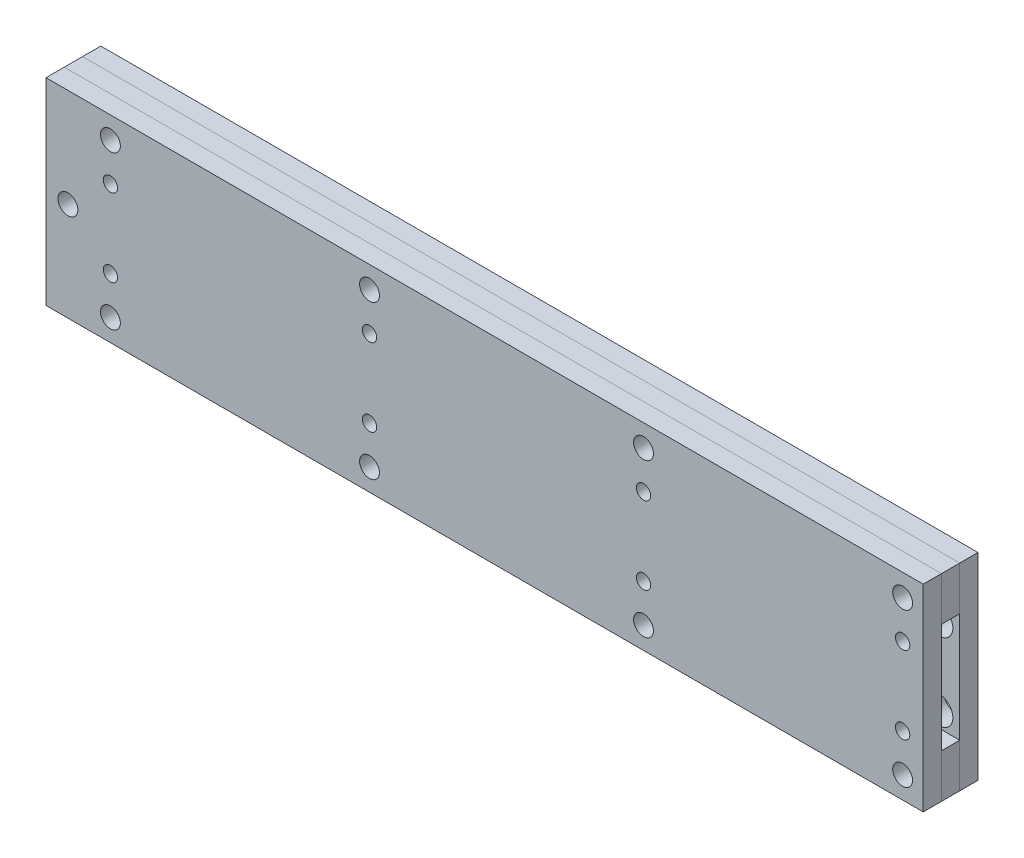
from build123d import *

# Parameters (mm, degrees)
CROQUIS3_W              = 304.927
CROQUIS3_H              = 68.58
CROQUIS3_R              = 2.4892
CROQUIS3_R_2            = 4.75615
SALIENTE_EXTRUIR1_DEPTH = 6.35
CROQUIS4_R              = 2.4892
SALIENTE_EXTRUIR2_DEPTH = 6.35
CROQUIS7_W              = 304.927
CROQUIS7_H              = 68.58
CROQUIS7_R              = 2.4892
CROQUIS7_R_2            = 3.45
SALIENTE_EXTRUIR4_DEPTH = 6.35


with BuildPart() as part:
    # Croquis3 → Saliente-Extruir1 (new body)
    with BuildSketch(Plane.XY):
        with Locations((-7.62, 0)):
            Rectangle(CROQUIS3_W, CROQUIS3_H)
        with Locations((-137.6934, -26.67)):
            Circle(CROQUIS3_R, mode=Mode.SUBTRACT)
        with Locations((-47.625, -26.67)):
            Circle(CROQUIS3_R, mode=Mode.SUBTRACT)
        with Locations((-137.6934, -13.4874)):
            Circle(CROQUIS3_R_2, mode=Mode.SUBTRACT)
        with Locations((-47.625, -13.4874)):
            Circle(CROQUIS3_R_2, mode=Mode.SUBTRACT)
        with Locations((47.625, -26.67)):
            Circle(CROQUIS3_R, mode=Mode.SUBTRACT)
        with Locations((137.6934, -26.67)):
            Circle(CROQUIS3_R, mode=Mode.SUBTRACT)
        with Locations((47.625, -13.4874)):
            Circle(CROQUIS3_R_2, mode=Mode.SUBTRACT)
        with Locations((137.6934, -13.4874)):
            Circle(CROQUIS3_R_2, mode=Mode.SUBTRACT)
        with Locations((-152.4635, 0)):
            Circle(CROQUIS3_R, mode=Mode.SUBTRACT)
        with Locations((-137.6934, 13.4874)):
            Circle(CROQUIS3_R_2, mode=Mode.SUBTRACT)
        with Locations((-47.625, 13.4874)):
            Circle(CROQUIS3_R_2, mode=Mode.SUBTRACT)
        with Locations((-137.6934, 26.67)):
            Circle(CROQUIS3_R, mode=Mode.SUBTRACT)
        with Locations((-47.625, 26.67)):
            Circle(CROQUIS3_R, mode=Mode.SUBTRACT)
        with Locations((47.625, 13.4874)):
            Circle(CROQUIS3_R_2, mode=Mode.SUBTRACT)
        with Locations((137.6934, 13.4874)):
            Circle(CROQUIS3_R_2, mode=Mode.SUBTRACT)
        with Locations((47.625, 26.67)):
            Circle(CROQUIS3_R, mode=Mode.SUBTRACT)
        with Locations((137.6934, 26.67)):
            Circle(CROQUIS3_R, mode=Mode.SUBTRACT)
    extrude(amount=SALIENTE_EXTRUIR1_DEPTH)


with BuildPart() as body_2:
    # Croquis4 → Saliente-Extruir2 (new body)
    with BuildSketch(Plane.XY.offset(6.35)):
        Polygon((144.8435, -19.05), (-144.8435, -19.05), (-144.8435, 19.05), (144.8435, 19.05), (144.8435, 34.29), (-160.0835, 34.29), (-160.0835, -34.29), (144.8435, -34.29), align=None)
        with Locations((-137.6934, -26.67)):
            Circle(CROQUIS4_R, mode=Mode.SUBTRACT)
        with Locations((-47.625, -26.67)):
            Circle(CROQUIS4_R, mode=Mode.SUBTRACT)
        with Locations((47.625, -26.67)):
            Circle(CROQUIS4_R, mode=Mode.SUBTRACT)
        with Locations((137.6934, -26.67)):
            Circle(CROQUIS4_R, mode=Mode.SUBTRACT)
        with Locations((-152.4635, 0)):
            Circle(CROQUIS4_R, mode=Mode.SUBTRACT)
        with Locations((-137.6934, 26.67)):
            Circle(CROQUIS4_R, mode=Mode.SUBTRACT)
        with Locations((-47.625, 26.67)):
            Circle(CROQUIS4_R, mode=Mode.SUBTRACT)
        with Locations((47.625, 26.67)):
            Circle(CROQUIS4_R, mode=Mode.SUBTRACT)
        with Locations((137.6934, 26.67)):
            Circle(CROQUIS4_R, mode=Mode.SUBTRACT)
    extrude(amount=SALIENTE_EXTRUIR2_DEPTH)


with BuildPart() as body_3:
    # Croquis7 → Saliente-Extruir4 (new body)
    with BuildSketch(Plane.XY.offset(12.7)):
        with Locations((-7.62, 0)):
            Rectangle(CROQUIS7_W, CROQUIS7_H)
        with Locations((-137.6934, 13.4874)):
            Circle(CROQUIS7_R, mode=Mode.SUBTRACT)
        with Locations((-152.4635, 0)):
            Circle(CROQUIS7_R_2, mode=Mode.SUBTRACT)
        with Locations((-137.6934, 26.67)):
            Circle(CROQUIS7_R_2, mode=Mode.SUBTRACT)
        with Locations((-47.625, 26.67)):
            Circle(CROQUIS7_R_2, mode=Mode.SUBTRACT)
        with Locations((47.625, 26.67)):
            Circle(CROQUIS7_R_2, mode=Mode.SUBTRACT)
        with Locations((137.6934, 26.67)):
            Circle(CROQUIS7_R_2, mode=Mode.SUBTRACT)
        with Locations((137.6934, -26.67)):
            Circle(CROQUIS7_R_2, mode=Mode.SUBTRACT)
        with Locations((47.625, -26.67)):
            Circle(CROQUIS7_R_2, mode=Mode.SUBTRACT)
        with Locations((-47.625, -26.67)):
            Circle(CROQUIS7_R_2, mode=Mode.SUBTRACT)
        with Locations((-137.6934, -26.67)):
            Circle(CROQUIS7_R_2, mode=Mode.SUBTRACT)
        with Locations((-137.6934, -13.4874)):
            Circle(CROQUIS7_R, mode=Mode.SUBTRACT)
        with Locations((-47.625, 13.4874)):
            Circle(CROQUIS7_R, mode=Mode.SUBTRACT)
        with Locations((-47.625, -13.4874)):
            Circle(CROQUIS7_R, mode=Mode.SUBTRACT)
        with Locations((47.625, -13.4874)):
            Circle(CROQUIS7_R, mode=Mode.SUBTRACT)
        with Locations((47.625, 13.4874)):
            Circle(CROQUIS7_R, mode=Mode.SUBTRACT)
        with Locations((137.6934, 13.4874)):
            Circle(CROQUIS7_R, mode=Mode.SUBTRACT)
        with Locations((137.6934, -13.4874)):
            Circle(CROQUIS7_R, mode=Mode.SUBTRACT)
    extrude(amount=SALIENTE_EXTRUIR4_DEPTH)


solid = Compound([part.part, body_2.part, body_3.part])
